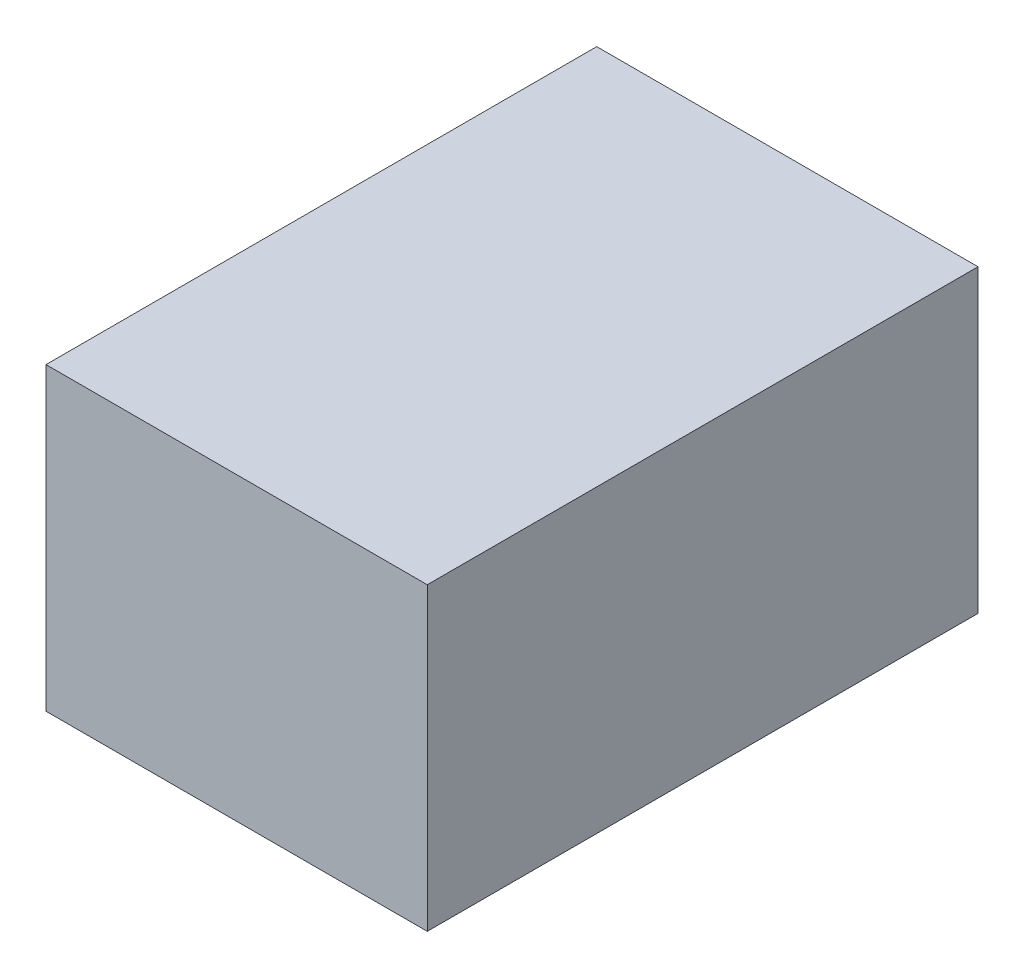
from build123d import *

# Parameters (mm, degrees)
SKETCH2_W           = 22.86
SKETCH2_H           = 33.02
BOSS_EXTRUDE1_DEPTH = 18


with BuildPart() as part:
    # Sketch2 → Boss-Extrude1 (new body)
    with BuildSketch(Plane(origin=(0, 0, 0), x_dir=(1, 0, 0), z_dir=(0, 1, 0))):
        Rectangle(SKETCH2_W, SKETCH2_H)
    extrude(amount=BOSS_EXTRUDE1_DEPTH)


solid = part.part
